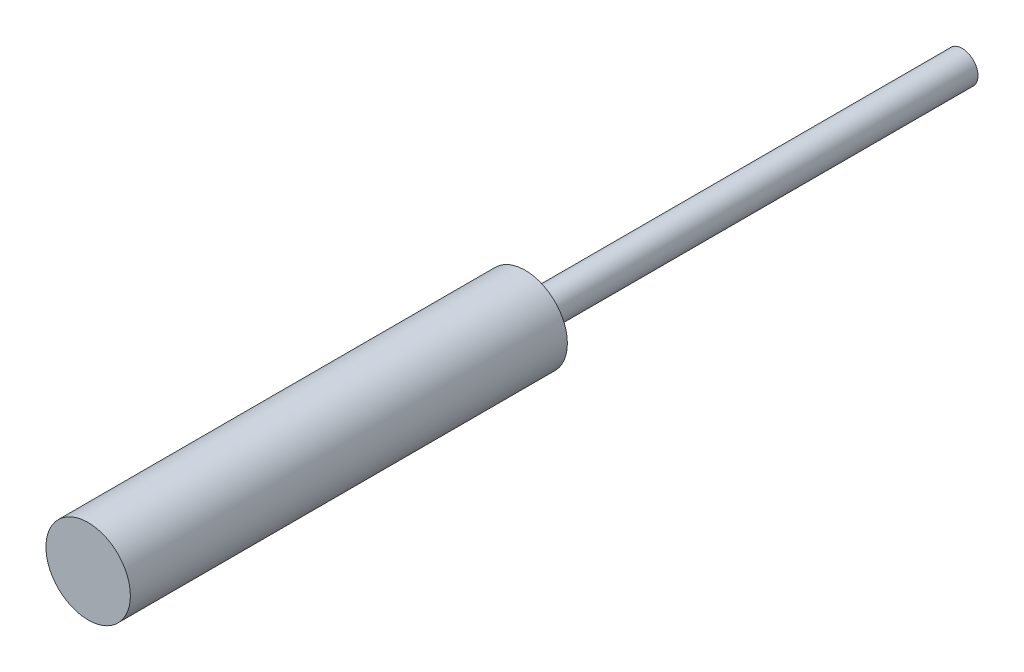
from build123d import *

# Parameters (mm, degrees)
SKETCH_1_R      = 2
EXTRUDE_1_DEPTH = 20.7
SKETCH_2_R      = 0.75
EXTRUDE_2_DEPTH = 20.7


with BuildPart() as part:
    # 草图1 → 凸台-拉伸1 (new body)
    with BuildSketch(Plane.XY):
        Circle(SKETCH_1_R)
    extrude(amount=EXTRUDE_1_DEPTH)

    # 草图2 → 凸台-拉伸2 (add)
    with BuildSketch(Plane(origin=(0, 0, 0), x_dir=(-1, 0, 0), z_dir=(0, 0, -1))):
        Circle(SKETCH_2_R)
    extrude(amount=EXTRUDE_2_DEPTH)


solid = part.part
